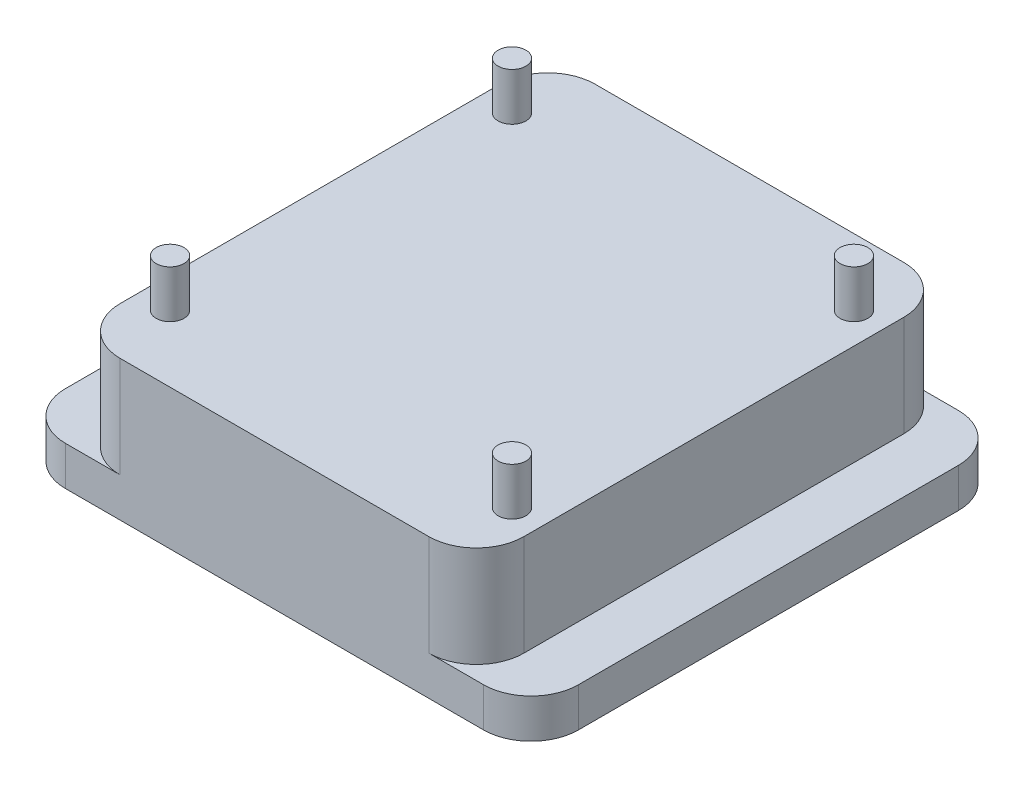
from build123d import *

# Parameters (mm, degrees)
SKETCH1_W           = 43.18
SKETCH1_H           = 7.62
SKETCH1_H_2         = 3.175
SKETCH1_W_2         = 54.864
SKETCH1_H_3         = 4.191
BOSS_EXTRUDE1_DEPTH = 50.8
SKETCH2_R           = 1.4859
BOSS_EXTRUDE2_DEPTH = 5.08
FILLET1_R           = 5.08
FILLET2_R           = 5.08


with BuildPart() as part:
    # Sketch1 → Boss-Extrude1 (new body)
    with BuildSketch(Plane.XY):
        with Locations((0, 9.0805)):
            Rectangle(SKETCH1_W, SKETCH1_H)
        with Locations((0, 3.683)):
            Rectangle(SKETCH1_W, SKETCH1_H_2)
        Rectangle(SKETCH1_W_2, SKETCH1_H_3)
    extrude(amount=BOSS_EXTRUDE1_DEPTH)

    # Sketch2 → Boss-Extrude2 (add)
    with BuildSketch(Plane(origin=(0, 12.8905, 0), x_dir=(1, 0, 0), z_dir=(0, 1, 0))):
        with Locations((-18.288, -7.112)):
            Circle(SKETCH2_R)
        with Locations((18.288, -7.112)):
            Circle(SKETCH2_R)
        with Locations((18.288, -43.688)):
            Circle(SKETCH2_R)
        with Locations((-18.288, -43.688)):
            Circle(SKETCH2_R)
    extrude(amount=BOSS_EXTRUDE2_DEPTH)

    # Fillet1
    fillet1_edges = [part.edges().sort_by_distance(p)[0] for p in [
        (21.59, 7.493, 0),
        (-21.59, 7.493, 0),
        (21.59, 7.493, 50.8),
        (-21.59, 7.493, 50.8),
    ]]
    fillet(fillet1_edges, radius=FILLET1_R)

    # Fillet2
    fillet2_edges = [part.edges().sort_by_distance(p)[0] for p in [
        (27.432, 0, 0),
        (-27.432, 0, 0),
        (-27.432, 0, 50.8),
        (27.432, 0, 50.8),
    ]]
    fillet(fillet2_edges, radius=FILLET2_R)


solid = part.part
